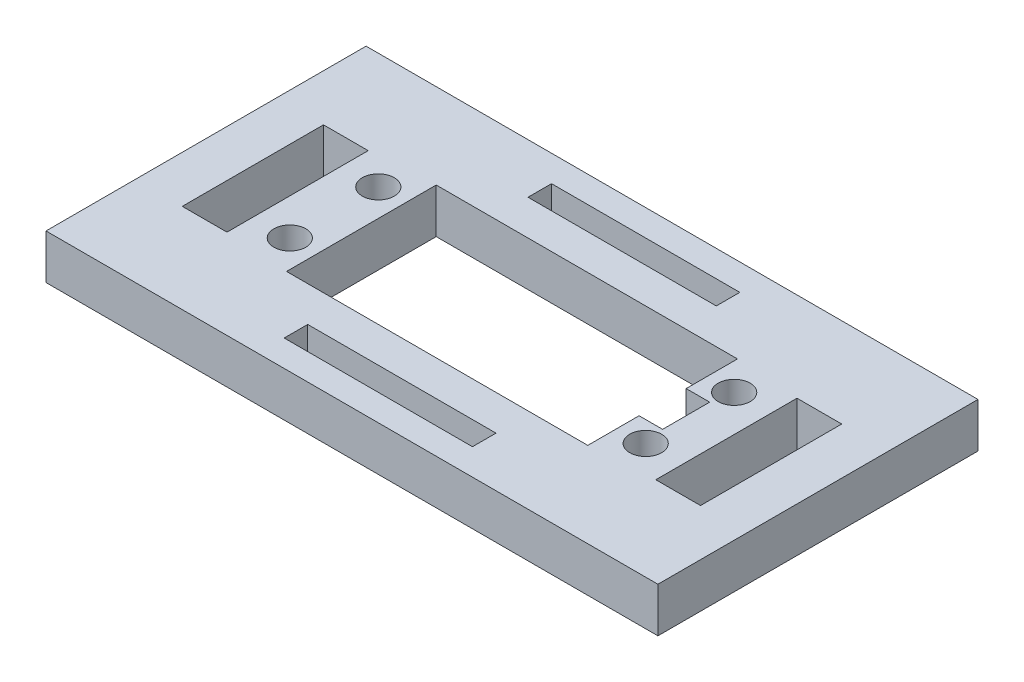
from build123d import *

# Parameters (mm, degrees)
SKETCH1_W           = 82.55
SKETCH1_H           = 43.18
SKETCH1_R           = 2.159
SKETCH1_W_2         = 40.64
SKETCH1_H_2         = 20.193
SKETCH1_W_3         = 25.4
SKETCH1_H_3         = 3.175
SKETCH1_W_4         = 6.0325
SKETCH1_H_4         = 19.05
BOSS_EXTRUDE1_DEPTH = 6.0325
SKETCH2_W           = 3.175
SKETCH2_H           = 6.35
CUT_EXTRUDE1_DEPTH  = 6.0325


with BuildPart() as part:
    # Sketch1 → Boss-Extrude1 (new body)
    with BuildSketch(Plane(origin=(0, 0, 0), x_dir=(1, 0, 0), z_dir=(0, 1, 0))):
        with Locations((20.32, 10.0965)):
            Rectangle(SKETCH1_W, SKETCH1_H)
        with Locations((44.323, 16.0655)):
            Circle(SKETCH1_R, mode=Mode.SUBTRACT)
        with Locations((44.323, 4.1275)):
            Circle(SKETCH1_R, mode=Mode.SUBTRACT)
        with Locations((-3.683, 4.1275)):
            Circle(SKETCH1_R, mode=Mode.SUBTRACT)
        with Locations((-3.683, 16.0655)):
            Circle(SKETCH1_R, mode=Mode.SUBTRACT)
        with Locations((20.32, 10.0965)):
            Rectangle(SKETCH1_W_2, SKETCH1_H_2, mode=Mode.SUBTRACT)
        with Locations((20.32, -6.35)):
            Rectangle(SKETCH1_W_3, SKETCH1_H_3, mode=Mode.SUBTRACT)
        with Locations((20.32, 26.543)):
            Rectangle(SKETCH1_W_3, SKETCH1_H_3, mode=Mode.SUBTRACT)
        with Locations((-11.6205, 10.0965)):
            Rectangle(SKETCH1_W_4, SKETCH1_H_4, mode=Mode.SUBTRACT)
        with Locations((52.2605, 10.0965)):
            Rectangle(SKETCH1_W_4, SKETCH1_H_4, mode=Mode.SUBTRACT)
    extrude(amount=BOSS_EXTRUDE1_DEPTH)

    # Sketch2 → Cut-Extrude1 (cut)
    with BuildSketch(Plane(origin=(0, 6.0325, 0), x_dir=(1, 0, 0), z_dir=(0, 1, 0))):
        with Locations((42.2275, 10.0965)):
            Rectangle(SKETCH2_W, SKETCH2_H)
    extrude(amount=-CUT_EXTRUDE1_DEPTH, mode=Mode.SUBTRACT)


solid = part.part
